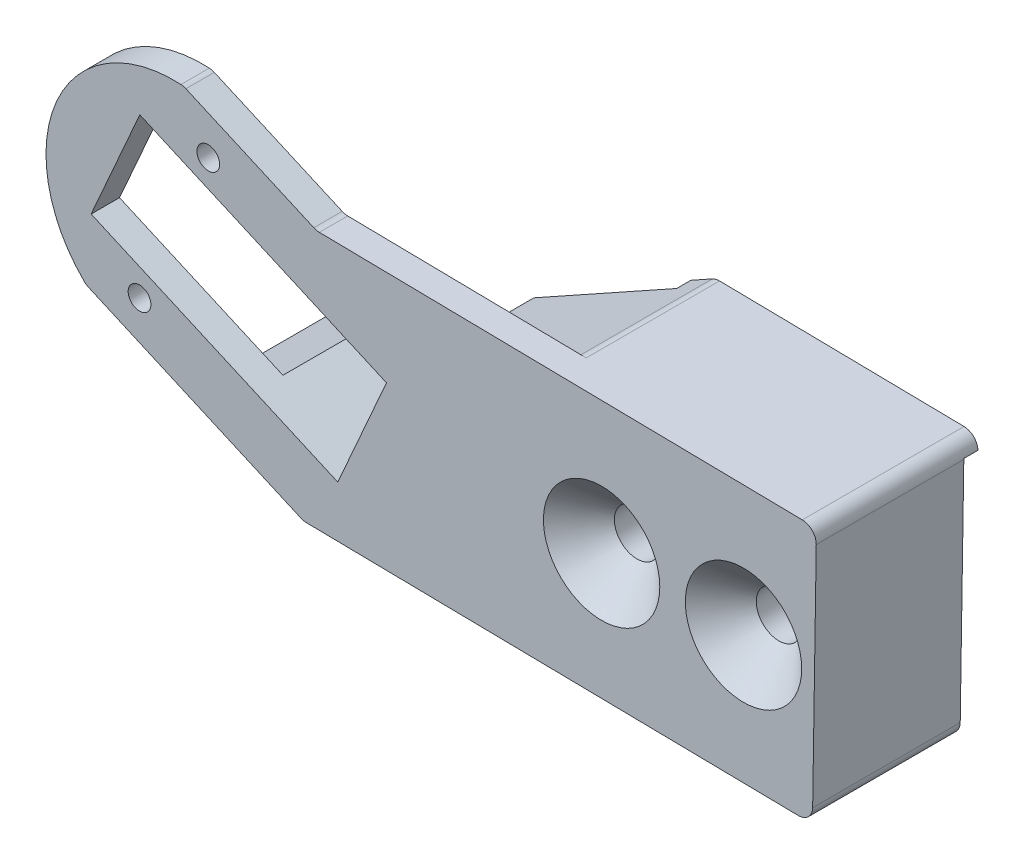
from build123d import *

# Parameters (mm, degrees)
SKETCH7_R           = 1.5999999999999968
SKETCH7_R_2         = 1.6000000000000103
BOSS_EXTRUDE4_DEPTH = 8.4
SKETCH8_R           = 1.600000000000002
SKETCH8_R_2         = 1.5999999999999888
SKETCH8_R_3         = 0.7999999999999944
BOSS_EXTRUDE5_DEPTH = 2
BOSS_EXTRUDE6_DEPTH = 1
CHAMFER1_SIZE       = 2.5
FILLET1_R           = 1
CUT_EXTRUDE1_DEPTH  = 20


with BuildPart() as part:
    # Sketch7 → Boss-Extrude4 (new body)
    with BuildSketch(Plane.XY):
        Polygon((100.70057064402273, 168.9698255115625), (92.5965029309412, 172.54522201163132), (118.3568955070623, 186.88533735497072), (136.85548909280223, 186.59587048571208), (136.570892648763, 168.40852501258752), align=None)
        with Locations((131.71257875478256, 177.50219774914976)):
            Circle(SKETCH7_R, mode=Mode.SUBTRACT)
        with Locations((121.71257875478257, 177.50219774914976)):
            Circle(SKETCH7_R_2, mode=Mode.SUBTRACT)
    extrude(amount=BOSS_EXTRUDE4_DEPTH)

    # Sketch8 → Boss-Extrude5 (add)
    with BuildSketch(Plane.XY.offset(8.4)):
        with BuildLine():
            Line((101.6151007105908, 187.14731375350308), (136.85548909280223, 186.59587048571208))
            Line((136.85548909280223, 186.59587048571208), (136.570892648763, 168.40852501258752))
            Line((136.570892648763, 168.40852501258752), (100.70057064402273, 168.96982551156256))
            Line((100.70057064402273, 168.96982551156256), (85.39263791538717, 175.72346220846532))
            ThreePointArc((85.39263791538717, 175.72346220846532), (83.32145188451928, 185.9277220686207), (92.25463791536886, 191.27701344283787))
            Line((92.25463791536886, 191.27701344283787), (101.6151007105908, 187.14731375350308))
        make_face()
        with Locations((121.71257875478257, 177.50219774914976)):
            Circle(SKETCH8_R, mode=Mode.SUBTRACT)
        with Locations((131.71257875478256, 177.50219774914976)):
            Circle(SKETCH8_R_2, mode=Mode.SUBTRACT)
        with Locations((93.99026460379022, 187.77878532013932)):
            Circle(SKETCH8_R_3, mode=Mode.SUBTRACT)
        with Locations((89.1464998979208, 176.79980797822924)):
            Circle(SKETCH8_R_3, mode=Mode.SUBTRACT)
    extrude(amount=BOSS_EXTRUDE5_DEPTH)

    # Sketch9 → Boss-Extrude6 (add)
    with BuildSketch(Plane(origin=(0, 0, 0), x_dir=(-1, 0, 0), z_dir=(0, 0, -1))):
        Polygon((-136.8406818403388, 185.64960210569163), (-136.85548909280223, 186.59587048571208), (-118.3568955070623, 186.88533735497072), (-116.60058674528226, 185.9076476653427), align=None)
    extrude(amount=BOSS_EXTRUDE6_DEPTH)

    # Chamfer1
    chamfer1_edges = [part.edges().sort_by_distance(p)[0] for p in [
        (120.11257875478256, 177.50219774914976, 10.4),
        (130.11257875478256, 177.50219774914976, 10.4),
    ]]
    chamfer(chamfer1_edges, length=CHAMFER1_SIZE)

    # Fillet1
    fillet1_edges = [part.edges().sort_by_distance(p)[0] for p in [
        (92.25463791536886, 191.27701344283787, 9.4),
        (85.39263791538717, 175.72346220846532, 9.4),
        (136.85548909280223, 186.59587048571208, 4.7),
        (136.570892648763, 168.40852501258752, 5.2),
        (100.70057064402273, 168.96982551156253, 5.2),
        (101.6151007105908, 187.14731375350308, 9.4),
        (118.3568955070623, 186.88533735497072, 3.7),
    ]]
    fillet(fillet1_edges, radius=FILLET1_R)

    # Sketch10 → Cut-Extrude1 (cut)
    with BuildSketch(Plane.XY.offset(10.400000000000002)):
        Polygon((93.96999875407636, 176.58449707589014), (85.73576574764382, 180.21732060529217), (89.16676574763467, 187.99409622247845), (97.40099875406719, 184.3612726930764), (106.55014653899221, 180.32480210485187), (103.11914653900139, 172.54802648766562), align=None)
    extrude(amount=-CUT_EXTRUDE1_DEPTH, mode=Mode.SUBTRACT)


solid = part.part
